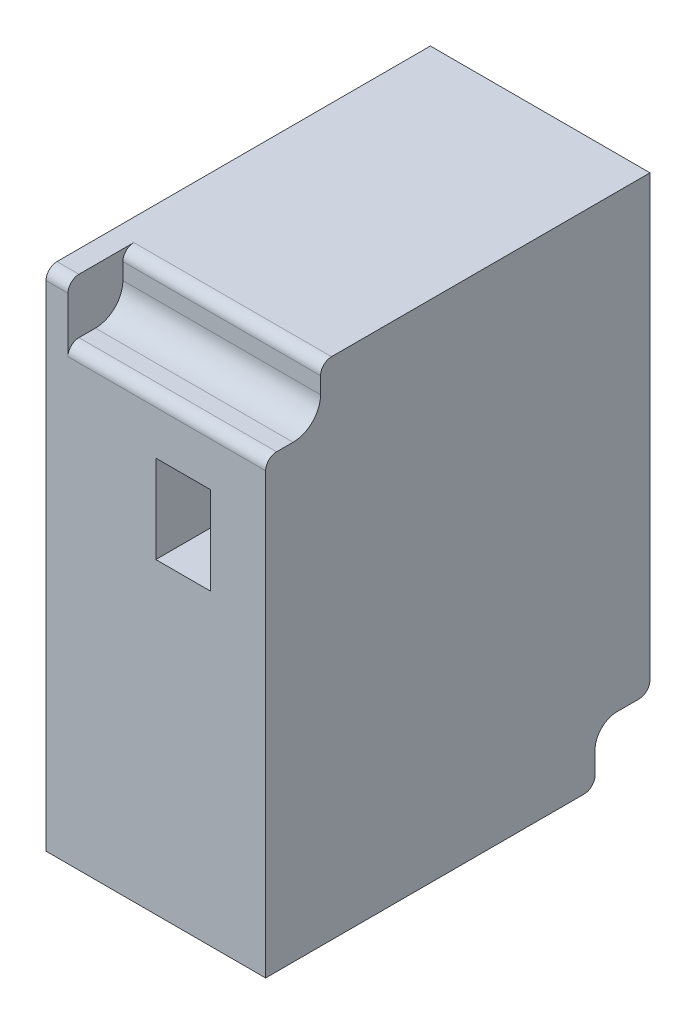
from build123d import *

# Parameters (mm, degrees)
SKETCH1_W           = 20
SKETCH1_H           = 46
BOSS_EXTRUDE1_DEPTH = 35
SKETCH2_W           = 5
SKETCH2_H           = 8
CUT_EXTRUDE1_DEPTH  = 5
FILLET1_R           = 2.5
FILLET2_R           = 1
FILLET3_R           = 1
SKETCH3_R           = 9
SKETCH3_R_2         = 6.5
CUT_EXTRUDE2_DEPTH  = 5
FILLET4_R           = 2
FILLET5_R           = 1


with BuildPart() as part:
    # Sketch1 → Boss-Extrude1 (new body)
    with BuildSketch(Plane.XY):
        with Locations((10, 23)):
            Rectangle(SKETCH1_W, SKETCH1_H)
    extrude(amount=-BOSS_EXTRUDE1_DEPTH)

    # Sketch2 → Cut-Extrude1 (cut)
    with BuildSketch(Plane.XY):
        Polygon((10, 41), (2, 41), (2, 46), (20, 46), (20, 41), align=None)
        with Locations((12.5, 32)):
            Rectangle(SKETCH2_W, SKETCH2_H)
    extrude(amount=-CUT_EXTRUDE1_DEPTH, mode=Mode.SUBTRACT)

    # Fillet1
    fillet1_edges = [part.edges().sort_by_distance(p)[0] for p in [
        (11, 41, -5),
    ]]
    fillet(fillet1_edges, radius=FILLET1_R)

    # Fillet2
    fillet2_edges = [part.edges().sort_by_distance(p)[0] for p in [
        (1, 46, 0),
    ]]
    fillet(fillet2_edges, radius=FILLET2_R)

    # Fillet3
    fillet3_edges = [part.edges().sort_by_distance(p)[0] for p in [
        (11, 46, -5),
        (11, 41, 0),
    ]]
    fillet(fillet3_edges, radius=FILLET3_R)

    # Sketch3 → Cut-Extrude2 (cut)
    with BuildSketch(Plane(origin=(0, 0, -35), x_dir=(-1, 0, 0), z_dir=(0, 0, -1))):
        with Locations((-10, 36)):
            Circle(SKETCH3_R)
        with Locations((-10, 36)):
            Circle(SKETCH3_R_2, mode=Mode.SUBTRACT)
        Polygon((-10, 5), (-20, 5), (-20, 0), (-5, 0), (-5, 5), align=None)
    extrude(amount=-CUT_EXTRUDE2_DEPTH, mode=Mode.SUBTRACT)

    # Fillet4
    fillet4_edges = [part.edges().sort_by_distance(p)[0] for p in [
        (12.5, 5, -30),
    ]]
    fillet(fillet4_edges, radius=FILLET4_R)

    # Fillet5
    fillet5_edges = [part.edges().sort_by_distance(p)[0] for p in [
        (12.5, 0, -30),
        (12.5, 5, -35),
        (2.5, 0, -35),
    ]]
    fillet(fillet5_edges, radius=FILLET5_R)


solid = part.part
